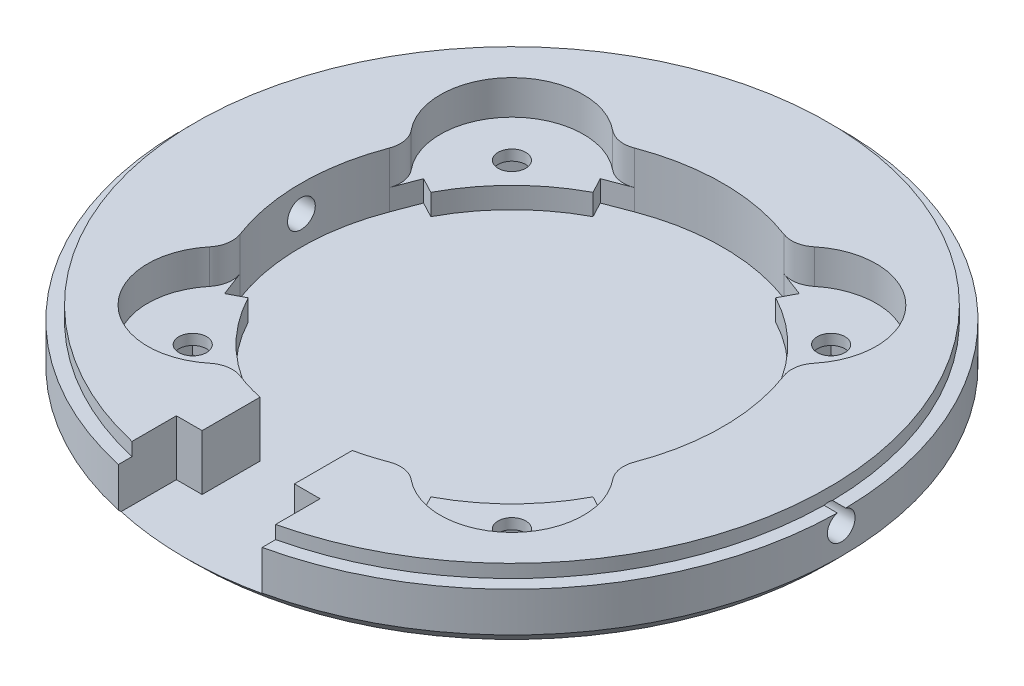
from build123d import *

# Parameters (mm, degrees)
SKETCH1_R               = 25
BOSS_EXTRUDE1_DEPTH     = 5
CUT_EXTRUDE1_START      = 5
CUT_EXTRUDE1_DEPTH      = 2.6
SKETCH1_5_R             = 1.05
CUT_EXTRUDE2_DEPTH      = 6
CUT_EXTRUDE4_DEPTH      = 1.6
CUT_EXTRUDE5_DEPTH      = 1.6
SKETCH5_W               = 7
SKETCH5_H               = 25
CUT_EXTRUDE6_DEPTH      = 4.2
SKETCH6_W               = 10.9
SKETCH6_H               = 5
CUT_EXTRUDE7_DEPTH      = 5.2
SKETCH7_W               = 1
SKETCH7_H               = 1
SKETCH8_R               = 1.05
CUT_EXTRUDE8_DEPTH      = 26
CUT_EXTRUDE8_DEPTH_BACK = 26


with BuildPart() as part:
    # Sketch1 → Boss-Extrude1 (new body)
    with BuildSketch(Plane(origin=(0, 0, 0), x_dir=(1, 0, 0), z_dir=(0, 1, 0))):
        Circle(SKETCH1_R)
    extrude(amount=BOSS_EXTRUDE1_DEPTH)

    # Sketch1_4 → Cut-Extrude1 (cut)
    with BuildSketch(Plane(origin=(0, 0, 0), x_dir=(1, 0, 0), z_dir=(0, 1, 0)).offset(CUT_EXTRUDE1_START)):
        with BuildLine():
            ThreePointArc((-7.646663173, 15.290666359), (-14.941166286, 14.941166286), (-15.290666359, 7.646663173))
            ThreePointArc((-15.290666359, 7.646663173), (-14.860391858, 6.700345618), (-14.963208205, 5.665898006))
            ThreePointArc((-14.963208205, 5.665898006), (-16, 0), (-14.963208205, -5.665898006))
            ThreePointArc((-14.963208205, -5.665898006), (-14.860391858, -6.700345618), (-15.290666359, -7.646663173))
            ThreePointArc((-15.290666359, -7.646663173), (-14.941166286, -14.941166286), (-7.646663173, -15.290666359))
            ThreePointArc((-7.646663173, -15.290666359), (-6.700345618, -14.860391858), (-5.665898006, -14.963208205))
            ThreePointArc((-5.665898006, -14.963208205), (0, -16), (5.665898006, -14.963208205))
            ThreePointArc((5.665898006, -14.963208205), (6.700345618, -14.860391858), (7.646663173, -15.290666359))
            ThreePointArc((7.646663173, -15.290666359), (14.941166286, -14.941166286), (15.290666359, -7.646663173))
            ThreePointArc((15.290666359, -7.646663173), (14.860391858, -6.700345618), (14.963208205, -5.665898006))
            ThreePointArc((14.963208205, -5.665898006), (16, 0), (14.963208205, 5.665898006))
            ThreePointArc((14.963208205, 5.665898006), (14.860391858, 6.700345618), (15.290666359, 7.646663173))
            ThreePointArc((15.290666359, 7.646663173), (14.941166286, 14.941166286), (7.646663173, 15.290666359))
            ThreePointArc((7.646663173, 15.290666359), (6.700345618, 14.860391858), (5.665898006, 14.963208205))
            ThreePointArc((5.665898006, 14.963208205), (0, 16), (-5.665898006, 14.963208205))
            ThreePointArc((-5.665898006, 14.963208205), (-6.700345618, 14.860391858), (-7.646663173, 15.290666359))
        make_face()
    extrude(amount=-CUT_EXTRUDE1_DEPTH, mode=Mode.SUBTRACT)

    # Sketch1_5 → Cut-Extrude2 (cut, through all)
    with BuildSketch(Plane(origin=(0, 0, 0), x_dir=(1, 0, 0), z_dir=(0, 1, 0))):
        with Locations((12.105668094, 12.105668094)):
            Circle(SKETCH1_5_R)
        with Locations((12.105668094, -12.105668094)):
            Circle(SKETCH1_5_R)
        with Locations((-12.105668094, -12.105668094)):
            Circle(SKETCH1_5_R)
        with Locations((-12.105668094, 12.105668094)):
            Circle(SKETCH1_5_R)
    extrude(amount=CUT_EXTRUDE2_DEPTH, mode=Mode.SUBTRACT)

    # Sketch3 → Cut-Extrude4 (cut)
    with BuildSketch(Plane(origin=(0, 2.4, 0), x_dir=(1, 0, 0), z_dir=(0, 1, 0))):
        with BuildLine():
            Line((-14.250424192, -7.548306686), (-13.078556304, -6.927580025))
            ThreePointArc((-13.078556304, -6.927580025), (-10.465180362, -10.465180362), (-6.927580025, -13.078556304))
            Line((-6.927580025, -13.078556304), (-7.548306686, -14.250424192))
            Line((-7.548306686, -14.250424192), (-5.665898006, -14.963208205))
            ThreePointArc((-5.665898006, -14.963208205), (0, -16), (5.665898006, -14.963208205))
            Line((5.665898006, -14.963208205), (7.548306686, -14.250424192))
            Line((7.548306686, -14.250424192), (6.927580025, -13.078556304))
            ThreePointArc((6.927580025, -13.078556304), (10.465180362, -10.465180362), (13.078556304, -6.927580025))
            Line((13.078556304, -6.927580025), (14.250424192, -7.548306686))
            Line((14.250424192, -7.548306686), (14.963208205, -5.665898006))
            ThreePointArc((14.963208205, -5.665898006), (16, 0), (14.963208205, 5.665898006))
            Line((14.963208205, 5.665898006), (14.250424192, 7.548306686))
            Line((14.250424192, 7.548306686), (13.078556304, 6.927580025))
            ThreePointArc((13.078556304, 6.927580025), (10.465180362, 10.465180362), (6.927580025, 13.078556304))
            Line((6.927580025, 13.078556304), (7.548306686, 14.250424192))
            Line((7.548306686, 14.250424192), (5.665898006, 14.963208205))
            ThreePointArc((5.665898006, 14.963208205), (0, 16), (-5.665898006, 14.963208205))
            Line((-5.665898006, 14.963208205), (-7.548306686, 14.250424192))
            Line((-7.548306686, 14.250424192), (-6.927580025, 13.078556304))
            ThreePointArc((-6.927580025, 13.078556304), (-10.465180362, 10.465180362), (-13.078556304, 6.927580025))
            Line((-13.078556304, 6.927580025), (-14.250424192, 7.548306686))
            Line((-14.250424192, 7.548306686), (-14.963208205, 5.665898006))
            ThreePointArc((-14.963208205, 5.665898006), (-16, 0), (-14.963208205, -5.665898006))
            Line((-14.963208205, -5.665898006), (-14.250424192, -7.548306686))
        make_face()
    extrude(amount=-CUT_EXTRUDE4_DEPTH, mode=Mode.SUBTRACT)

    # Sketch4 → Cut-Extrude5 (cut)
    with BuildSketch(Plane.XZ):
        Polygon((-10.391025274, 13.820310914), (-12.733270924, 14.447913744), (-14.447913744, 12.733270924), (-13.820310914, 10.391025274), (-11.478065263, 9.763422443), (-9.763422443, 11.478065263), align=None)
        Polygon((13.820310914, 10.391025274), (14.447913744, 12.733270924), (12.733270924, 14.447913744), (10.391025274, 13.820310914), (9.763422443, 11.478065263), (11.478065263, 9.763422443), align=None)
        Polygon((10.391025274, -13.820310914), (12.733270924, -14.447913744), (14.447913744, -12.733270924), (13.820310914, -10.391025274), (11.478065263, -9.763422443), (9.763422443, -11.478065263), align=None)
        Polygon((-13.820310914, -10.391025274), (-14.447913744, -12.733270924), (-12.733270924, -14.447913744), (-10.391025274, -13.820310914), (-9.763422443, -11.478065263), (-11.478065263, -9.763422443), align=None)
    extrude(amount=-CUT_EXTRUDE5_DEPTH, mode=Mode.SUBTRACT)

    # Sketch5 → Cut-Extrude6 (cut)
    with BuildSketch(Plane(origin=(0, 5, 0), x_dir=(1, 0, 0), z_dir=(0, 1, 0))):
        with Locations((0, -12.5)):
            Rectangle(SKETCH5_W, SKETCH5_H)
    extrude(amount=-CUT_EXTRUDE6_DEPTH, mode=Mode.SUBTRACT)

    # Sketch6 → Cut-Extrude7 (cut, through all)
    with BuildSketch(Plane(origin=(0, 0.8, 0), x_dir=(1, 0, 0), z_dir=(0, 1, 0))):
        with Locations((0, -22.5)):
            Rectangle(SKETCH6_W, SKETCH6_H)
    extrude(amount=CUT_EXTRUDE7_DEPTH, mode=Mode.SUBTRACT)

    # Sketch7 → Cut-Revolve1 (revolve, cut)
    with BuildSketch(Plane.XY):
        Polygon((-25, 1), (-24, 0), (-25, 0), align=None)
        with Locations((-24.5, 4.5)):
            Rectangle(SKETCH7_W, SKETCH7_H)
    revolve(axis=Axis((0, 5.25, 0), (0, -1, 0)), mode=Mode.SUBTRACT)

    # Sketch8 → Cut-Extrude8 (cut, two sides)
    with BuildSketch(Plane(origin=(0, 0, 0), x_dir=(0, 0, -1), z_dir=(1, 0, 0))) as cut_extrude8_sk:
        with Locations((0, 3)):
            Circle(SKETCH8_R)
    extrude(amount=CUT_EXTRUDE8_DEPTH, mode=Mode.SUBTRACT)
    extrude(cut_extrude8_sk.sketch, amount=-CUT_EXTRUDE8_DEPTH_BACK, mode=Mode.SUBTRACT)


solid = part.part
